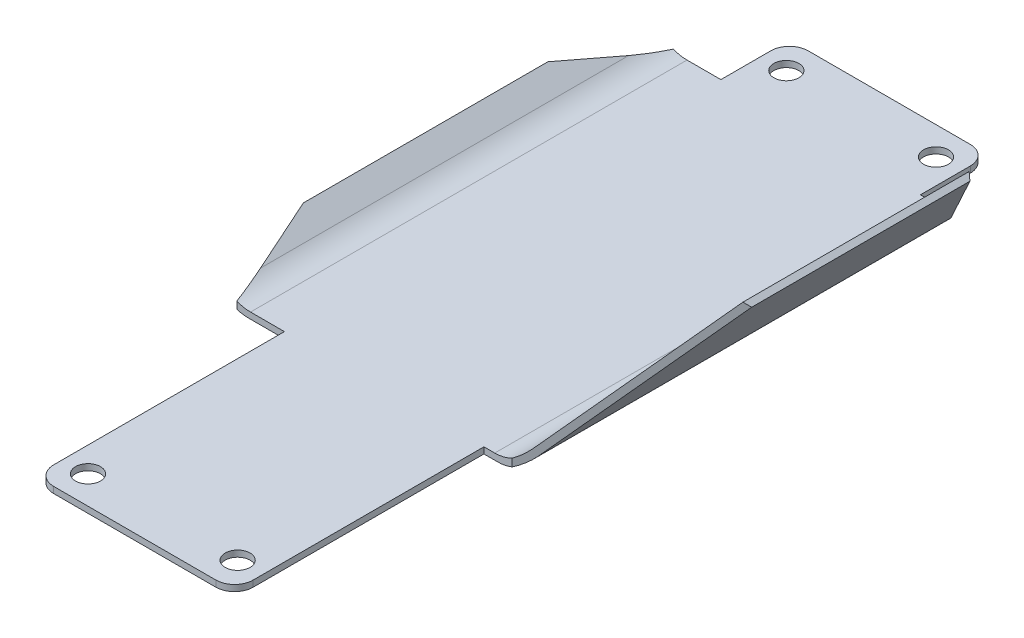
from build123d import *

# Parameters (mm, degrees)
SKETCH1_R           = 2
BOSS_EXTRUDE1_DEPTH = 1
BOSS_EXTRUDE2_DEPTH = 70
CUT_EXTRUDE1_DEPTH  = 70
FILLET1_R           = 6
FILLET2_R           = 6


with BuildPart() as part:
    # Sketch1 → Boss-Extrude1 (new body)
    with BuildSketch(Plane(origin=(0, 0, 0), x_dir=(1, 0, 0), z_dir=(0, 1, 0))):
        with BuildLine():
            Line((-12.999999999999979, -60.5), (12.99999999999998, -60.5))
            ThreePointArc((12.99999999999998, -60.5), (15.121320343559649, -59.62132034355964), (16, -57.49999999999997))
            Line((16, -57.49999999999997), (16, 57.49999999999997))
            ThreePointArc((16, 57.49999999999997), (15.121320343559649, 59.62132034355964), (12.99999999999998, 60.5))
            Line((12.99999999999998, 60.5), (-12.999999999999979, 60.5))
            ThreePointArc((-12.999999999999979, 60.5), (-15.121320343559644, 59.62132034355963), (-16, 57.49999999999997))
            Line((-16, 57.49999999999997), (-16, -57.49999999999997))
            ThreePointArc((-16, -57.49999999999997), (-15.121320343559649, -59.62132034355964), (-12.999999999999979, -60.5))
        make_face()
        with Locations(Location((-12, 56, 0), (0, 0, 270))):
            Circle(SKETCH1_R, mode=Mode.SUBTRACT)
        with Locations(Location((12, 56, 0), (0, 0, 90))):
            Circle(SKETCH1_R, mode=Mode.SUBTRACT)
        with Locations(Location((12, -56, 0), (0, 0, 270))):
            Circle(SKETCH1_R, mode=Mode.SUBTRACT)
        with Locations(Location((-12, -56, 0), (0, 0, 90))):
            Circle(SKETCH1_R, mode=Mode.SUBTRACT)
    extrude(amount=BOSS_EXTRUDE1_DEPTH)

    # Sketch2 → Boss-Extrude2 (add)
    with BuildSketch(Plane.XY.offset(20.499999999999996)):
        Polygon((-23.633274615316285, 1), (20.533692341844997, 1), (40.67208349009961, 25.000000000000004), (41.43812793321859, 24.357212390313464), (20.999999999999996, 0), (-24, -9.1e-16), (-28.999999999999993, 4.237089446732834), (-28.353495949190116, 4.9999999999999964), align=None)
    extrude(amount=-BOSS_EXTRUDE2_DEPTH)

    # Sketch3 → Cut-Extrude1 (cut)
    with BuildSketch(Plane.XZ):
        Polygon((20.999999999999996, 20.499999999999996), (20.999999999999996, 20.109633851053125), (40.672083490099595, 3.6412886727309868), (40.67208349009961, 20.499999999999993), align=None)
        Polygon((20.999999999999996, 20.499999999999996), (20.533692341844997, 20.499999999999996), (20.999999999999993, 20.109633851053125), align=None)
        Polygon((40.67208349009961, 20.499999999999993), (40.67208349009961, 3.6412886727309868), (41.43812793321859, 2.9999999999999964), (41.43812793321859, 20.499999999999993), align=None)
        Polygon((41.43812793321859, -32.00000000000001), (40.67208349009961, -32.64128867273098), (40.67208349009961, -49.50000000000001), (41.43812793321859, -49.50000000000001), align=None)
        Polygon((40.67208349009961, -32.64128867273098), (20.999999999999996, -49.10963385105313), (20.999999999999996, -49.5), (40.67208349009961, -49.50000000000001), align=None)
        Polygon((-24, -49.50000000000001), (-23.633274615316285, -49.50000000000001), (-24.00000000000002, -48.30416943816782), align=None)
        Polygon((-24, -49.50000000000001), (-24, -48.30416943816781), (-28.353495949190155, -34.108142317373115), (-28.353495949190116, -49.5), align=None)
        Polygon((-28.353495949190116, -49.5), (-28.353495949190116, -34.10814231737311), (-28.999999999999993, -32.00000000000001), (-28.999999999999993, -49.5), align=None)
        Polygon((-24.00000000000002, 19.304169438167804), (-23.633274615316285, 20.499999999999996), (-24, 20.499999999999996), align=None)
        Polygon((-28.353495949190116, 5.108142317373225), (-24.00000000000002, 19.304169438167804), (-24, 20.499999999999993), (-28.353495949190116, 20.499999999999996), align=None)
        Polygon((-28.999999999999993, 2.9999999999999964), (-28.353495949190116, 5.108142317373225), (-28.353495949190116, 20.499999999999996), (-28.999999999999993, 20.499999999999996), align=None)
        Polygon((20.999999999999996, -49.10963385105313), (20.533692341844997, -49.50000000000001), (20.999999999999996, -49.50000000000001), align=None)
    extrude(amount=-CUT_EXTRUDE1_DEPTH, mode=Mode.SUBTRACT)

    # Fillet1
    fillet1_edges = [part.edges().sort_by_distance(p)[0] for p in [
        (-23.633274615316285, 1, -14.500000000000004),
        (20.533692341844997, 1, -14.500000000000004),
    ]]
    fillet(fillet1_edges, radius=FILLET1_R)

    # Fillet2
    fillet2_edges = [part.edges().sort_by_distance(p)[0] for p in [
        (-24, -9.1e-16, -14.50000000000001),
        (20.999999999999996, 0, -14.500000000000004),
    ]]
    fillet(fillet2_edges, radius=FILLET2_R)


solid = part.part
